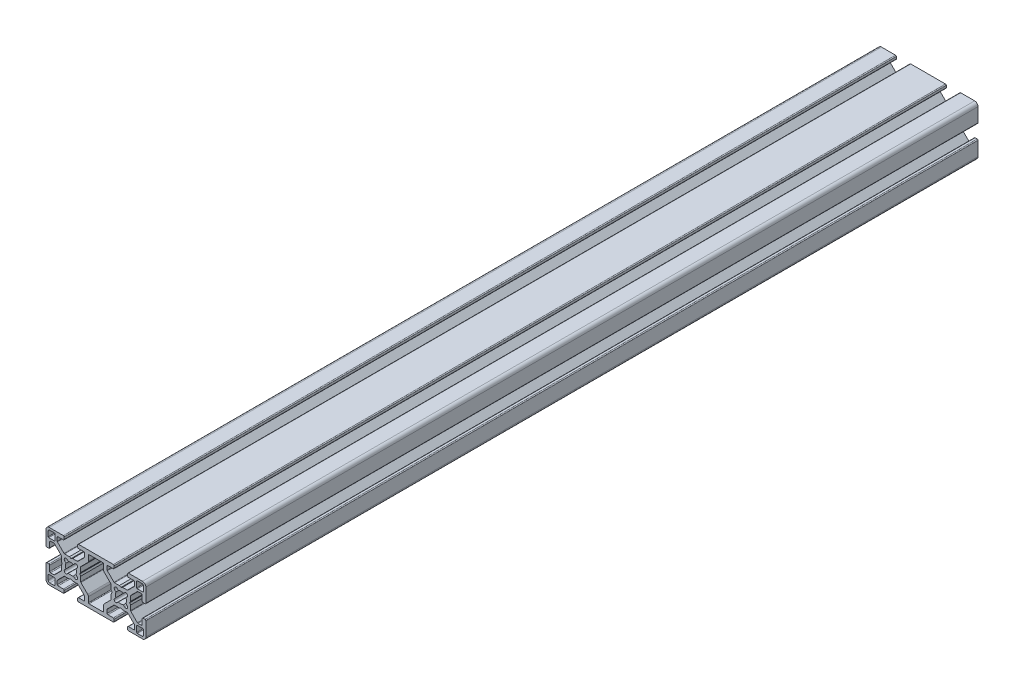
from build123d import *

# Parameters (mm, degrees)
EXTRUDE1_DEPTH = 500


with BuildPart() as part:
    # Sketch1 → Extrude1 (new body)
    with BuildSketch(Plane.XY):
        with BuildLine():
            Line((-10.428, -15), (10.428, -15))
            ThreePointArc((10.428, -15), (10.787210245, -14.851210245), (10.936, -14.492))
            Line((10.936, -14.492), (10.936, -13.2982))
            ThreePointArc((10.936, -13.2982), (10.787210245, -12.938989755), (10.428, -12.7902))
            Line((10.428, -12.7902), (7.253, -12.7902))
            ThreePointArc((7.253, -12.7902), (6.893789755, -12.641410245), (6.745, -12.2822))
            Line((6.745, -12.2822), (6.745, -10.261471714))
            ThreePointArc((6.745, -10.261471714), (6.783669197, -10.06706853), (6.893789755, -9.902261469))
            Line((6.893789755, -9.902261469), (10.825246067, -5.970805157))
            ThreePointArc((10.825246067, -5.970805157), (10.990053129, -5.860684599), (11.184456312, -5.822015402))
            Line((11.184456312, -5.822015402), (14.0475, -5.822015402))
            Line((14.0475, -5.822015402), (15, -5.314015402))
            Line((15, -5.314015402), (15.9525, -5.822015402))
            Line((15.9525, -5.822015402), (18.815543688, -5.822015402))
            ThreePointArc((18.815543688, -5.822015402), (19.009946871, -5.860684599), (19.174753933, -5.970805157))
            Line((19.174753933, -5.970805157), (23.106210245, -9.902261469))
            ThreePointArc((23.106210245, -9.902261469), (23.216330803, -10.06706853), (23.255, -10.261471714))
            Line((23.255, -10.261471714), (23.255, -12.2822))
            ThreePointArc((23.255, -12.2822), (23.106210245, -12.641410245), (22.747, -12.7902))
            Line((22.747, -12.7902), (19.572, -12.7902))
            ThreePointArc((19.572, -12.7902), (19.212789755, -12.938989755), (19.064, -13.2982))
            Line((19.064, -13.2982), (19.064, -14.492))
            ThreePointArc((19.064, -14.492), (19.212789755, -14.851210245), (19.572, -15))
            Line((19.572, -15), (27.9934, -15))
            ThreePointArc((27.9934, -15), (29.412280467, -14.412280467), (30, -12.9934))
            Line((30, -12.9934), (30, -4.572))
            ThreePointArc((30, -4.572), (29.851210245, -4.212789755), (29.492, -4.064))
            Line((29.492, -4.064), (28.2982, -4.064))
            ThreePointArc((28.2982, -4.064), (27.938989755, -4.212789755), (27.7902, -4.572))
            Line((27.7902, -4.572), (27.7902, -7.747))
            ThreePointArc((27.7902, -7.747), (27.641410245, -8.106210245), (27.2822, -8.255))
            Line((27.2822, -8.255), (25.261471714, -8.255))
            ThreePointArc((25.261471714, -8.255), (25.06706853, -8.216330803), (24.902261469, -8.106210245))
            Line((24.902261469, -8.106210245), (20.970805157, -4.174753933))
            ThreePointArc((20.970805157, -4.174753933), (20.860684599, -4.009946871), (20.822015402, -3.815543688))
            Line((20.822015402, -3.815543688), (20.822015402, -0.9525))
            Line((20.822015402, -0.9525), (20.314015402, 0))
            Line((20.314015402, 0), (20.822015402, 0.9525))
            Line((20.822015402, 0.9525), (20.822015402, 3.815543688))
            ThreePointArc((20.822015402, 3.815543688), (20.860684599, 4.009946871), (20.970805157, 4.174753933))
            Line((20.970805157, 4.174753933), (24.902261469, 8.106210245))
            ThreePointArc((24.902261469, 8.106210245), (25.06706853, 8.216330803), (25.261471714, 8.255))
            Line((25.261471714, 8.255), (27.2822, 8.255))
            ThreePointArc((27.2822, 8.255), (27.641410245, 8.106210245), (27.7902, 7.747))
            Line((27.7902, 7.747), (27.7902, 4.572))
            ThreePointArc((27.7902, 4.572), (27.938989755, 4.212789755), (28.2982, 4.064))
            Line((28.2982, 4.064), (29.492, 4.064))
            ThreePointArc((29.492, 4.064), (29.851210245, 4.212789755), (30, 4.572))
            Line((30, 4.572), (30, 12.9934))
            ThreePointArc((30, 12.9934), (29.412280467, 14.412280467), (27.9934, 15))
            Line((27.9934, 15), (19.572, 15))
            ThreePointArc((19.572, 15), (19.212789755, 14.851210245), (19.064, 14.492))
            Line((19.064, 14.492), (19.064, 13.2982))
            ThreePointArc((19.064, 13.2982), (19.212789755, 12.938989755), (19.572, 12.7902))
            Line((19.572, 12.7902), (22.747, 12.7902))
            ThreePointArc((22.747, 12.7902), (23.106210245, 12.641410245), (23.255, 12.2822))
            Line((23.255, 12.2822), (23.255, 10.261471714))
            ThreePointArc((23.255, 10.261471714), (23.216330803, 10.06706853), (23.106210245, 9.902261469))
            Line((23.106210245, 9.902261469), (19.174753933, 5.970805157))
            ThreePointArc((19.174753933, 5.970805157), (19.009946871, 5.860684599), (18.815543688, 5.822015402))
            Line((18.815543688, 5.822015402), (15.9525, 5.822015402))
            Line((15.9525, 5.822015402), (15, 5.314015402))
            Line((15, 5.314015402), (14.0475, 5.822015402))
            Line((14.0475, 5.822015402), (11.184456312, 5.822015402))
            ThreePointArc((11.184456312, 5.822015402), (10.990053129, 5.860684599), (10.825246067, 5.970805157))
            Line((10.825246067, 5.970805157), (6.893789755, 9.902261469))
            ThreePointArc((6.893789755, 9.902261469), (6.783669197, 10.06706853), (6.745, 10.261471714))
            Line((6.745, 10.261471714), (6.745, 12.2822))
            ThreePointArc((6.745, 12.2822), (6.893789755, 12.641410245), (7.253, 12.7902))
            Line((7.253, 12.7902), (10.428, 12.7902))
            ThreePointArc((10.428, 12.7902), (10.787210245, 12.938989755), (10.936, 13.2982))
            Line((10.936, 13.2982), (10.936, 14.492))
            ThreePointArc((10.936, 14.492), (10.787210245, 14.851210245), (10.428, 15))
            Line((10.428, 15), (-10.428, 15))
            ThreePointArc((-10.428, 15), (-10.787210245, 14.851210245), (-10.936, 14.492))
            Line((-10.936, 14.492), (-10.936, 13.2982))
            ThreePointArc((-10.936, 13.2982), (-10.787210245, 12.938989755), (-10.428, 12.7902))
            Line((-10.428, 12.7902), (-7.253, 12.7902))
            ThreePointArc((-7.253, 12.7902), (-6.893789755, 12.641410245), (-6.745, 12.2822))
            Line((-6.745, 12.2822), (-6.745, 10.261471714))
            ThreePointArc((-6.745, 10.261471714), (-6.783669197, 10.06706853), (-6.893789755, 9.902261469))
            Line((-6.893789755, 9.902261469), (-10.825246067, 5.970805157))
            ThreePointArc((-10.825246067, 5.970805157), (-10.990053129, 5.860684599), (-11.184456312, 5.822015402))
            Line((-11.184456312, 5.822015402), (-14.0475, 5.822015402))
            Line((-14.0475, 5.822015402), (-15, 5.314015402))
            Line((-15, 5.314015402), (-15.9525, 5.822015402))
            Line((-15.9525, 5.822015402), (-18.815543688, 5.822015402))
            ThreePointArc((-18.815543688, 5.822015402), (-19.009946871, 5.860684599), (-19.174753933, 5.970805157))
            Line((-19.174753933, 5.970805157), (-23.106210245, 9.902261469))
            ThreePointArc((-23.106210245, 9.902261469), (-23.216330803, 10.06706853), (-23.255, 10.261471714))
            Line((-23.255, 10.261471714), (-23.255, 12.2822))
            ThreePointArc((-23.255, 12.2822), (-23.106210245, 12.641410245), (-22.747, 12.7902))
            Line((-22.747, 12.7902), (-19.572, 12.7902))
            ThreePointArc((-19.572, 12.7902), (-19.212789755, 12.938989755), (-19.064, 13.2982))
            Line((-19.064, 13.2982), (-19.064, 14.492))
            ThreePointArc((-19.064, 14.492), (-19.212789755, 14.851210245), (-19.572, 15))
            Line((-19.572, 15), (-27.9934, 15))
            ThreePointArc((-27.9934, 15), (-29.412280467, 14.412280467), (-30, 12.9934))
            Line((-30, 12.9934), (-30, 4.572))
            ThreePointArc((-30, 4.572), (-29.851210245, 4.212789755), (-29.492, 4.064))
            Line((-29.492, 4.064), (-28.2982, 4.064))
            ThreePointArc((-28.2982, 4.064), (-27.938989755, 4.212789755), (-27.7902, 4.572))
            Line((-27.7902, 4.572), (-27.7902, 7.747))
            ThreePointArc((-27.7902, 7.747), (-27.641410245, 8.106210245), (-27.2822, 8.255))
            Line((-27.2822, 8.255), (-25.261471714, 8.255))
            ThreePointArc((-25.261471714, 8.255), (-25.06706853, 8.216330803), (-24.902261469, 8.106210245))
            Line((-24.902261469, 8.106210245), (-20.970805157, 4.174753933))
            ThreePointArc((-20.970805157, 4.174753933), (-20.860684599, 4.009946871), (-20.822015402, 3.815543688))
            Line((-20.822015402, 3.815543688), (-20.822015402, 0.9525))
            Line((-20.822015402, 0.9525), (-20.314015402, 0))
            Line((-20.314015402, 0), (-20.822015402, -0.9525))
            Line((-20.822015402, -0.9525), (-20.822015402, -3.815543688))
            ThreePointArc((-20.822015402, -3.815543688), (-20.860684599, -4.009946871), (-20.970805157, -4.174753933))
            Line((-20.970805157, -4.174753933), (-24.902261469, -8.106210245))
            ThreePointArc((-24.902261469, -8.106210245), (-25.06706853, -8.216330803), (-25.261471714, -8.255))
            Line((-25.261471714, -8.255), (-27.2822, -8.255))
            ThreePointArc((-27.2822, -8.255), (-27.641410245, -8.106210245), (-27.7902, -7.747))
            Line((-27.7902, -7.747), (-27.7902, -4.572))
            ThreePointArc((-27.7902, -4.572), (-27.938989755, -4.212789755), (-28.2982, -4.064))
            Line((-28.2982, -4.064), (-29.492, -4.064))
            ThreePointArc((-29.492, -4.064), (-29.851210245, -4.212789755), (-30, -4.572))
            Line((-30, -4.572), (-30, -12.9934))
            ThreePointArc((-30, -12.9934), (-29.412280467, -14.412280467), (-27.9934, -15))
            Line((-27.9934, -15), (-19.572, -15))
            ThreePointArc((-19.572, -15), (-19.212789755, -14.851210245), (-19.064, -14.492))
            Line((-19.064, -14.492), (-19.064, -13.2982))
            ThreePointArc((-19.064, -13.2982), (-19.212789755, -12.938989755), (-19.572, -12.7902))
            Line((-19.572, -12.7902), (-22.747, -12.7902))
            ThreePointArc((-22.747, -12.7902), (-23.106210245, -12.641410245), (-23.255, -12.2822))
            Line((-23.255, -12.2822), (-23.255, -10.261471714))
            ThreePointArc((-23.255, -10.261471714), (-23.216330803, -10.06706853), (-23.106210245, -9.902261469))
            Line((-23.106210245, -9.902261469), (-19.174753933, -5.970805157))
            ThreePointArc((-19.174753933, -5.970805157), (-19.009946871, -5.860684599), (-18.815543688, -5.822015402))
            Line((-18.815543688, -5.822015402), (-15.9525, -5.822015402))
            Line((-15.9525, -5.822015402), (-15, -5.314015402))
            Line((-15, -5.314015402), (-14.0475, -5.822015402))
            Line((-14.0475, -5.822015402), (-11.184456312, -5.822015402))
            ThreePointArc((-11.184456312, -5.822015402), (-10.990053129, -5.860684599), (-10.825246067, -5.970805157))
            Line((-10.825246067, -5.970805157), (-6.893789755, -9.902261469))
            ThreePointArc((-6.893789755, -9.902261469), (-6.783669197, -10.06706853), (-6.745, -10.261471714))
            Line((-6.745, -10.261471714), (-6.745, -12.2822))
            ThreePointArc((-6.745, -12.2822), (-6.893789755, -12.641410245), (-7.253, -12.7902))
            Line((-7.253, -12.7902), (-10.428, -12.7902))
            ThreePointArc((-10.428, -12.7902), (-10.787210245, -12.938989755), (-10.936, -13.2982))
            Line((-10.936, -13.2982), (-10.936, -14.492))
            ThreePointArc((-10.936, -14.492), (-10.787210245, -14.851210245), (-10.428, -15))
        make_face()
        with BuildLine():
            Line((12.782541514, 3.726141514), (13.525717665, 2.982965363))
            ThreePointArc((13.525717665, 2.982965363), (15, 3.3274), (16.474282335, 2.982965363))
            Line((16.474282335, 2.982965363), (17.217458486, 3.726141514))
            ThreePointArc((17.217458486, 3.726141514), (18.726141514, 3.726141514), (18.726141514, 2.217458486))
            Line((18.726141514, 2.217458486), (17.982965363, 1.474282335))
            ThreePointArc((17.982965363, 1.474282335), (18.3274, 0), (17.982965363, -1.474282335))
            Line((17.982965363, -1.474282335), (18.726141514, -2.217458486))
            ThreePointArc((18.726141514, -2.217458486), (18.726141514, -3.726141514), (17.217458486, -3.726141514))
            Line((17.217458486, -3.726141514), (16.474282335, -2.982965363))
            ThreePointArc((16.474282335, -2.982965363), (15, -3.3274), (13.525717665, -2.982965363))
            Line((13.525717665, -2.982965363), (12.782541514, -3.726141514))
            ThreePointArc((12.782541514, -3.726141514), (11.273858486, -3.726141514), (11.273858486, -2.217458486))
            Line((11.273858486, -2.217458486), (12.017034637, -1.474282335))
            ThreePointArc((12.017034637, -1.474282335), (11.6726, 0), (12.017034637, 1.474282335))
            Line((12.017034637, 1.474282335), (11.273858486, 2.217458486))
            ThreePointArc((11.273858486, 2.217458486), (11.273858486, 3.726141514), (12.782541514, 3.726141514))
        make_face(mode=Mode.SUBTRACT)
        with BuildLine():
            Line((-28.7046, 9.8946), (-28.7046, 12.6886))
            ThreePointArc((-28.7046, 12.6886), (-28.40702049, 13.40702049), (-27.6886, 13.7046))
            Line((-27.6886, 13.7046), (-24.8946, 13.7046))
            ThreePointArc((-24.8946, 13.7046), (-24.625192316, 13.593007684), (-24.5136, 13.3236))
            Line((-24.5136, 13.3236), (-24.5136, 9.8946))
            ThreePointArc((-24.5136, 9.8946), (-24.625192316, 9.625192316), (-24.8946, 9.5136))
            Line((-24.8946, 9.5136), (-28.3236, 9.5136))
            ThreePointArc((-28.3236, 9.5136), (-28.593007684, 9.625192316), (-28.7046, 9.8946))
        make_face(mode=Mode.SUBTRACT)
        with BuildLine():
            Line((-24.8946, -13.7046), (-27.6886, -13.7046))
            ThreePointArc((-27.6886, -13.7046), (-28.40702049, -13.40702049), (-28.7046, -12.6886))
            Line((-28.7046, -12.6886), (-28.7046, -9.8946))
            ThreePointArc((-28.7046, -9.8946), (-28.593007684, -9.625192316), (-28.3236, -9.5136))
            Line((-28.3236, -9.5136), (-24.8946, -9.5136))
            ThreePointArc((-24.8946, -9.5136), (-24.625192316, -9.625192316), (-24.5136, -9.8946))
            Line((-24.5136, -9.8946), (-24.5136, -13.3236))
            ThreePointArc((-24.5136, -13.3236), (-24.625192316, -13.593007684), (-24.8946, -13.7046))
        make_face(mode=Mode.SUBTRACT)
        with BuildLine():
            Line((4.981569265, 8.22237951), (9.029194843, 4.174753933))
            ThreePointArc((9.029194843, 4.174753933), (9.139315401, 4.009946871), (9.177984598, 3.815543688))
            Line((9.177984598, 3.815543688), (9.177984598, 0.9525))
            Line((9.177984598, 0.9525), (9.685984598, 0))
            Line((9.685984598, 0), (9.177984598, -0.9525))
            Line((9.177984598, -0.9525), (9.177984598, -3.815543688))
            ThreePointArc((9.177984598, -3.815543688), (9.139315401, -4.009946871), (9.029194843, -4.174753933))
            Line((9.029194843, -4.174753933), (4.981569265, -8.22237951))
            ThreePointArc((4.981569265, -8.22237951), (4.651207592, -8.716800694), (4.5352, -9.300010245))
            Line((4.5352, -9.300010245), (4.5352, -12.4092))
            ThreePointArc((4.5352, -12.4092), (4.423607684, -12.678607684), (4.1542, -12.7902))
            Line((4.1542, -12.7902), (-4.1542, -12.7902))
            ThreePointArc((-4.1542, -12.7902), (-4.423607684, -12.678607684), (-4.5352, -12.4092))
            Line((-4.5352, -12.4092), (-4.5352, -9.300010245))
            ThreePointArc((-4.5352, -9.300010245), (-4.651207592, -8.716800694), (-4.981569265, -8.22237951))
            Line((-4.981569265, -8.22237951), (-9.029194843, -4.174753933))
            ThreePointArc((-9.029194843, -4.174753933), (-9.139315401, -4.009946871), (-9.177984598, -3.815543688))
            Line((-9.177984598, -3.815543688), (-9.177984598, -0.9525))
            Line((-9.177984598, -0.9525), (-9.685984598, 0))
            Line((-9.685984598, 0), (-9.177984598, 0.9525))
            Line((-9.177984598, 0.9525), (-9.177984598, 3.815543688))
            ThreePointArc((-9.177984598, 3.815543688), (-9.139315401, 4.009946871), (-9.029194843, 4.174753933))
            Line((-9.029194843, 4.174753933), (-4.981569265, 8.22237951))
            ThreePointArc((-4.981569265, 8.22237951), (-4.651207592, 8.716800694), (-4.5352, 9.300010245))
            Line((-4.5352, 9.300010245), (-4.5352, 12.4092))
            ThreePointArc((-4.5352, 12.4092), (-4.423607684, 12.678607684), (-4.1542, 12.7902))
            Line((-4.1542, 12.7902), (4.1542, 12.7902))
            ThreePointArc((4.1542, 12.7902), (4.423607684, 12.678607684), (4.5352, 12.4092))
            Line((4.5352, 12.4092), (4.5352, 9.300010245))
            ThreePointArc((4.5352, 9.300010245), (4.651207592, 8.716800694), (4.981569265, 8.22237951))
        make_face(mode=Mode.SUBTRACT)
        with BuildLine():
            Line((-18.726141514, -2.217458486), (-17.982965363, -1.474282335))
            ThreePointArc((-17.982965363, -1.474282335), (-18.3274, 0), (-17.982965363, 1.474282335))
            Line((-17.982965363, 1.474282335), (-18.726141514, 2.217458486))
            ThreePointArc((-18.726141514, 2.217458486), (-18.726141514, 3.726141514), (-17.217458486, 3.726141514))
            Line((-17.217458486, 3.726141514), (-16.474282335, 2.982965363))
            ThreePointArc((-16.474282335, 2.982965363), (-15, 3.3274), (-13.525717665, 2.982965363))
            Line((-13.525717665, 2.982965363), (-12.782541514, 3.726141514))
            ThreePointArc((-12.782541514, 3.726141514), (-11.273858486, 3.726141514), (-11.273858486, 2.217458486))
            Line((-11.273858486, 2.217458486), (-12.017034637, 1.474282335))
            ThreePointArc((-12.017034637, 1.474282335), (-11.6726, 0), (-12.017034637, -1.474282335))
            Line((-12.017034637, -1.474282335), (-11.273858486, -2.217458486))
            ThreePointArc((-11.273858486, -2.217458486), (-11.273858486, -3.726141514), (-12.782541514, -3.726141514))
            Line((-12.782541514, -3.726141514), (-13.525717665, -2.982965363))
            ThreePointArc((-13.525717665, -2.982965363), (-15, -3.3274), (-16.474282335, -2.982965363))
            Line((-16.474282335, -2.982965363), (-17.217458486, -3.726141514))
            ThreePointArc((-17.217458486, -3.726141514), (-18.726141514, -3.726141514), (-18.726141514, -2.217458486))
        make_face(mode=Mode.SUBTRACT)
        with BuildLine():
            Line((24.8946, 13.7046), (27.6886, 13.7046))
            ThreePointArc((27.6886, 13.7046), (28.40702049, 13.40702049), (28.7046, 12.6886))
            Line((28.7046, 12.6886), (28.7046, 9.8946))
            ThreePointArc((28.7046, 9.8946), (28.593007684, 9.625192316), (28.3236, 9.5136))
            Line((28.3236, 9.5136), (24.8946, 9.5136))
            ThreePointArc((24.8946, 9.5136), (24.625192316, 9.625192316), (24.5136, 9.8946))
            Line((24.5136, 9.8946), (24.5136, 13.3236))
            ThreePointArc((24.5136, 13.3236), (24.625192316, 13.593007684), (24.8946, 13.7046))
        make_face(mode=Mode.SUBTRACT)
        with BuildLine():
            Line((24.5136, -13.3236), (24.5136, -9.8946))
            ThreePointArc((24.5136, -9.8946), (24.625192316, -9.625192316), (24.8946, -9.5136))
            Line((24.8946, -9.5136), (28.3236, -9.5136))
            ThreePointArc((28.3236, -9.5136), (28.593007684, -9.625192316), (28.7046, -9.8946))
            Line((28.7046, -9.8946), (28.7046, -12.6886))
            ThreePointArc((28.7046, -12.6886), (28.40702049, -13.40702049), (27.6886, -13.7046))
            Line((27.6886, -13.7046), (24.8946, -13.7046))
            ThreePointArc((24.8946, -13.7046), (24.625192316, -13.593007684), (24.5136, -13.3236))
        make_face(mode=Mode.SUBTRACT)
    extrude(amount=-EXTRUDE1_DEPTH)


solid = part.part
